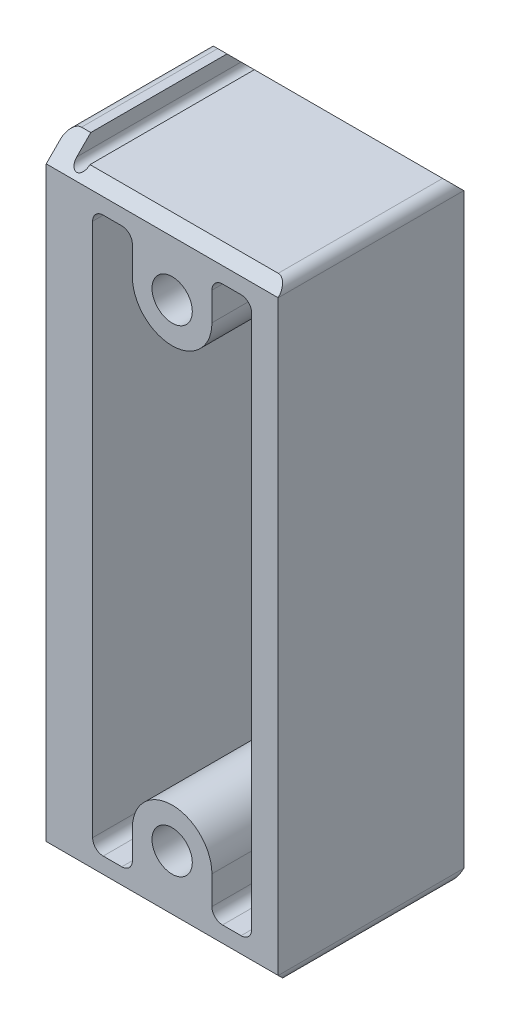
from build123d import *

# Parameters (mm, degrees)
SKETCH1_R            = 4.826
BOSS_EXTRUDE1_DEPTH  = 22.225
CUT_EXTRUDE2_DEPTH   = 45.45
CUT_EXTRUDE3_DEPTH   = 45.45
FILLET1_R            = 2.54
CUT_EXTRUDE4_DEPTH   = 56.5625
MIRROR3_COPY_1_DEPTH = 56.5625


with BuildPart() as part:
    # Sketch1 → Boss-Extrude1 (new body, symmetric)
    with BuildSketch(Plane.XY):
        Polygon((-25.4, 72.8218), (25.4, 72.8218), (25.4, -72.8218), (-25.4, -72.8218), (-25.4, -76.2), (-30.1625, -76.2), (-30.1625, 76.2), (-25.4, 76.2), align=None)
        with Locations((0, 57.15)):
            Circle(SKETCH1_R, mode=Mode.SUBTRACT)
        with Locations((0, -57.15)):
            Circle(SKETCH1_R, mode=Mode.SUBTRACT)
    extrude(amount=BOSS_EXTRUDE1_DEPTH, both=True)

    # Sketch3 → Cut-Extrude2 (cut, through all)
    with BuildSketch(Plane.XY.offset(22.225)):
        with BuildLine():
            Line((-19.05, 66.4718), (-9.525, 66.4718))
            Line((-9.525, 66.4718), (-9.525, 57.15))
            ThreePointArc((-9.525, 57.15), (0, 47.625), (9.525, 57.15))
            Line((9.525, 57.15), (9.525, 66.4718))
            Line((9.525, 66.4718), (19.05, 66.4718))
            Line((19.05, 66.4718), (19.05, 0))
            Line((19.05, 0), (-19.05, 0))
            Line((-19.05, 0), (-19.05, 66.4718))
        make_face()
    cut_extrude2 = extrude(amount=-CUT_EXTRUDE2_DEPTH, mode=Mode.SUBTRACT)

    # Sketch4 → Cut-Extrude3 (cut, through all)
    with BuildSketch(Plane.XY.offset(22.225)):
        with BuildLine():
            Line((-22.225, 72.8218), (-25.4, 72.8218))
            ThreePointArc((-25.4, 72.8218), (-23.8125, 71.2343), (-22.225, 72.8218))
        make_face()
    cut_extrude3 = extrude(amount=-CUT_EXTRUDE3_DEPTH, mode=Mode.SUBTRACT)

    # Mirror1: Cut-Extrude2, Cut-Extrude3 across plane
    add(cut_extrude2.mirror(Plane.ZX), mode=Mode.SUBTRACT)
    add(cut_extrude3.mirror(Plane.ZX), mode=Mode.SUBTRACT)

    # Fillet1
    fillet1_edges = [part.edges().sort_by_distance(p)[0] for p in [
        (25.4, 72.8218, 0),
        (25.4, -72.8218, 0),
        (-30.1625, -76.2, 0),
        (-30.1625, 76.2, 0),
        (-19.05, 66.4718, 0),
        (-9.525, 66.4718, 0),
        (9.525, 66.4718, 0),
        (19.05, 66.4718, 0),
        (-19.05, -66.4718, 0),
        (19.05, -66.4718, 0),
        (9.525, -66.4718, 0),
        (-9.525, -66.4718, 0),
    ]]
    fillet(fillet1_edges, radius=FILLET1_R)

    # Sketch5 → Cut-Extrude4 (cut, through all)
    with BuildSketch(Plane(origin=(25.4, 0, 0), x_dir=(0, 0, -1), z_dir=(1, 0, 0))):
        Polygon((16.3068, 76.2), (22.225, 70.2818), (22.225, 76.2), align=None)
    cut_extrude4 = extrude(amount=-CUT_EXTRUDE4_DEPTH, mode=Mode.SUBTRACT)

    # Mirror2: Cut-Extrude4 across plane
    add(cut_extrude4.mirror(Plane.XY), mode=Mode.SUBTRACT)

    # Mirror3: Cut-Extrude4 across plane
    add(cut_extrude4.mirror(Plane.ZX), mode=Mode.SUBTRACT)

    # Mirror3 copy 1 sketch → Mirror3 copy 1 (cut, through all)
    with BuildSketch(Plane(origin=(25.4, 0, 0), x_dir=(0, 0, 1), z_dir=(1, 0, 0))):
        Polygon((16.3068, 76.2), (22.225, 70.2818), (22.225, 76.2), align=None)
    extrude(amount=-MIRROR3_COPY_1_DEPTH, mode=Mode.SUBTRACT)


solid = part.part
